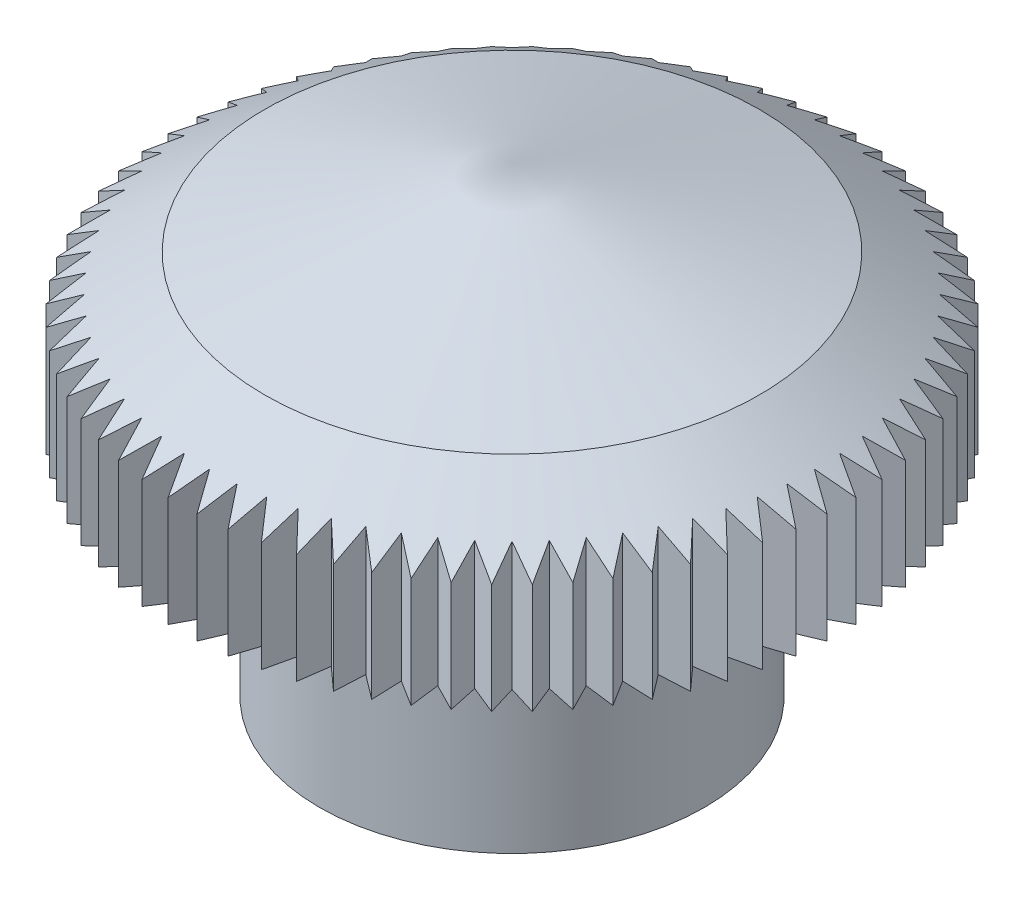
from build123d import *

# Parameters (mm, degrees)
CORTAR_EXTRUIR1_DEPTH          = 5.2
MATRIZC1_COUNT                 = 72
TALADRO_ROSCADO_M1X0_251_D     = 0.75
TALADRO_ROSCADO_M1X0_251_DEPTH = 2.5
TALADRO_ROSCADO_M1X0_251_TIP   = 0.225322732


with BuildPart() as part:
    # Croquis1 → Revolución1 (revolve)
    with BuildSketch(Plane.XY):
        Polygon((0, 4.2), (0, 0), (1, 0), (1, 2), (1.5, 2), (1.5, 0), (1.75, 0), (1.75, 2), (3, 2), (3, 3), (2.25, 3.5), align=None)
    revolve(axis=Axis((0, 4.2, 0), (0, -1, 0)))

    # Croquis3 → Cortar-Extruir1 (cut, through all)
    with BuildSketch(Plane(origin=(0, 0, 0), x_dir=(1, 0, 0), z_dir=(0, 1, 0))):
        with BuildLine():
            Line((-0.130858162, 2.997144665), (0, 2.75))
            Line((0, 2.75), (0.130858162, 2.997144665))
            ThreePointArc((0.130858162, 2.997144665), (0, 3), (-0.130858162, 2.997144665))
        make_face()
    cortar_extruir1 = extrude(amount=CORTAR_EXTRUIR1_DEPTH, mode=Mode.SUBTRACT)

    # MatrizC1: Cortar-Extruir1 ×72 about axis
    matrizc1_axis = Axis((0, 0, 0), (0, 1, 0))
    for i in range(1, MATRIZC1_COUNT):
        add(cortar_extruir1.rotate(matrizc1_axis, i * 360 / MATRIZC1_COUNT), mode=Mode.SUBTRACT)

    # Taladro roscado M1x0.251
    with Locations(Plane.XZ):
        with Locations((0, 0)):
            Hole(TALADRO_ROSCADO_M1X0_251_D / 2, depth=TALADRO_ROSCADO_M1X0_251_DEPTH)
            with Locations((0, 0, -(TALADRO_ROSCADO_M1X0_251_DEPTH + TALADRO_ROSCADO_M1X0_251_TIP / 2))):  # 118° drill point
                Cone(0, TALADRO_ROSCADO_M1X0_251_D / 2, TALADRO_ROSCADO_M1X0_251_TIP, mode=Mode.SUBTRACT)


solid = part.part
